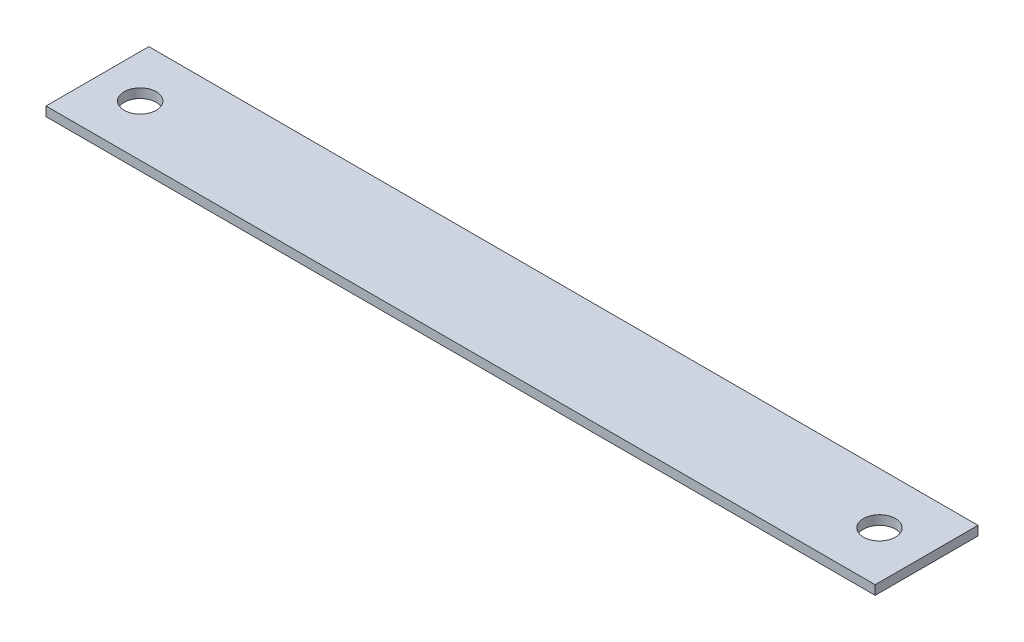
from build123d import *

# Parameters (mm, degrees)
SKETCH1_W           = 204.7875
SKETCH1_H           = 25.4
BOSS_EXTRUDE1_DEPTH = 2.286
SKETCH2_R           = 3.96875
CUT_EXTRUDE1_DEPTH  = 3.286


with BuildPart() as part:
    # Sketch1 → Boss-Extrude1 (new body)
    with BuildSketch(Plane(origin=(0, 0, 0), x_dir=(1, 0, 0), z_dir=(0, 1, 0))):
        with Locations((102.39375, 12.7)):
            Rectangle(SKETCH1_W, SKETCH1_H)
    extrude(amount=BOSS_EXTRUDE1_DEPTH)

    # Sketch2 → Cut-Extrude1 (cut, through all)
    with BuildSketch(Plane(origin=(0, 2.286, 0), x_dir=(1, 0, 0), z_dir=(0, 1, 0))):
        with Locations((10.5664, 12.7)):
            Circle(SKETCH2_R)
        with Locations((193.1543, 12.7)):
            Circle(SKETCH2_R)
    extrude(amount=-CUT_EXTRUDE1_DEPTH, mode=Mode.SUBTRACT)


solid = part.part
